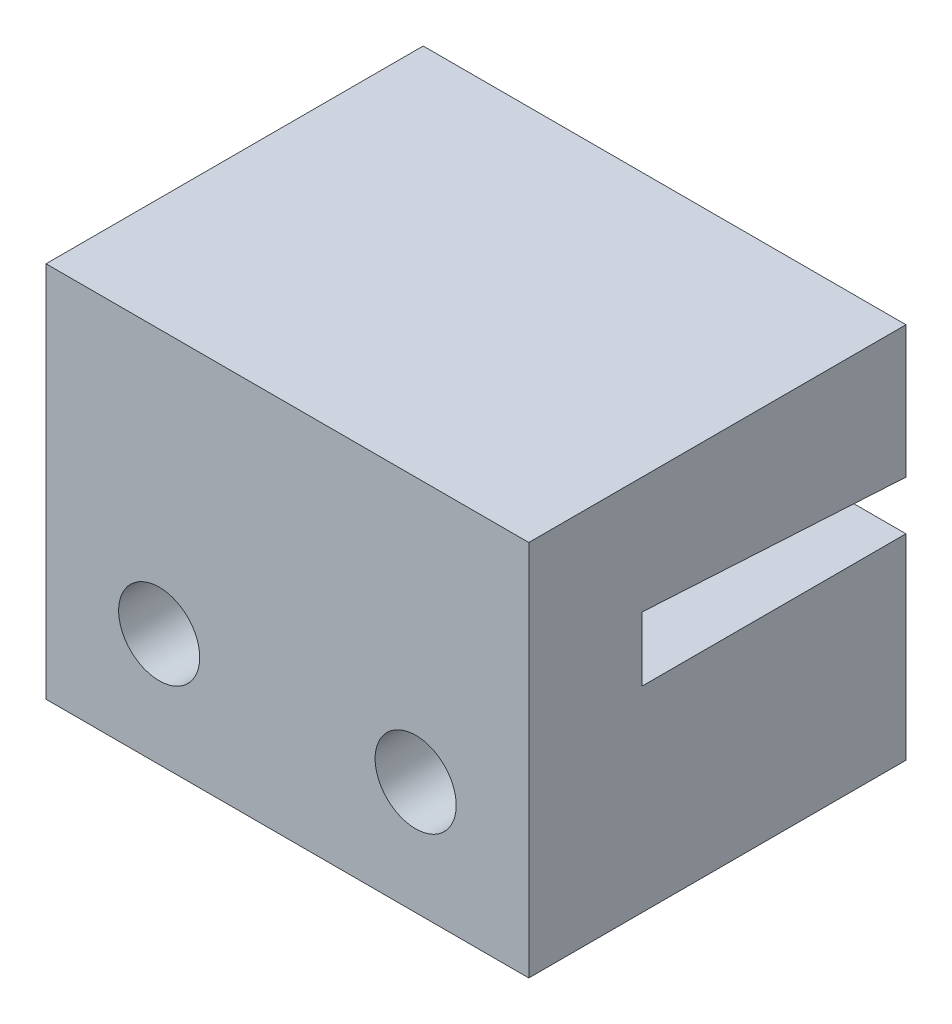
from build123d import *

# Parameters (mm, degrees)
BOSS_EXTRUDE1_DEPTH = 10
SKETCH1_3_W         = 12.8
SKETCH1_3_H         = 1.3
BOSS_EXTRUDE2_DEPTH = 7
SKETCH1_5_W         = 12.8
SKETCH1_5_H         = 1.3
CUT_EXTRUDE1_DEPTH  = 7
SKETCH1_6_R         = 1.075
CUT_EXTRUDE2_DEPTH  = 10
SKETCH4_W           = 12.8
SKETCH4_H           = 10
BOSS_EXTRUDE3_DEPTH = 1
CUT_EXTRUDE3_DEPTH  = 15
SKETCH8_W           = 12.8
SKETCH8_H           = 10
BOSS_EXTRUDE4_DEPTH = 1


with BuildPart() as part:
    # Sketch1 → Boss-Extrude1 (new body)
    with BuildSketch(Plane.XY):
        Polygon((6.4, 4), (-6.4, 4), (-6.4, -1), (-6.4, -4), (6.4, -4), (6.4, -1), align=None)
    extrude(amount=BOSS_EXTRUDE1_DEPTH)

    # Sketch1_3 → Boss-Extrude2 (add)
    with BuildSketch(Plane.XY):
        with Locations((0, 1.85)):
            Rectangle(SKETCH1_3_W, SKETCH1_3_H)
    extrude(amount=BOSS_EXTRUDE2_DEPTH)

    # Sketch1_5 → Cut-Extrude1 (cut)
    with BuildSketch(Plane.XY):
        with Locations((0, 1.85)):
            Rectangle(SKETCH1_5_W, SKETCH1_5_H)
    extrude(amount=CUT_EXTRUDE1_DEPTH, mode=Mode.SUBTRACT)

    # Sketch1_6 → Cut-Extrude2 (cut)
    with BuildSketch(Plane.XY):
        with Locations((-3.4, -1)):
            Circle(SKETCH1_6_R)
        with Locations((3.4, -1)):
            Circle(SKETCH1_6_R)
    extrude(amount=CUT_EXTRUDE2_DEPTH, mode=Mode.SUBTRACT)

    # Sketch4 → Boss-Extrude3 (add)
    with BuildSketch(Plane(origin=(0, 4, 0), x_dir=(1, 0, 0), z_dir=(0, 1, 0))):
        with Locations((0, -5)):
            Rectangle(SKETCH4_W, SKETCH4_H)
    extrude(amount=BOSS_EXTRUDE3_DEPTH)

    # Sketch6 → Cut-Extrude3 (cut)
    with BuildSketch(Plane(origin=(6.4, 0, 0), x_dir=(0, 0, -1), z_dir=(1, 0, 0))):
        Polygon((0, 2.5), (-7, 2.902751688), (-7, 2.5), align=None)
    extrude(amount=-CUT_EXTRUDE3_DEPTH, mode=Mode.SUBTRACT)

    # Sketch8 → Boss-Extrude4 (add)
    with BuildSketch(Plane(origin=(0, 5, 0), x_dir=(1, 0, 0), z_dir=(0, 1, 0))):
        with Locations((0, -5)):
            Rectangle(SKETCH8_W, SKETCH8_H)
    extrude(amount=BOSS_EXTRUDE4_DEPTH)


solid = part.part
